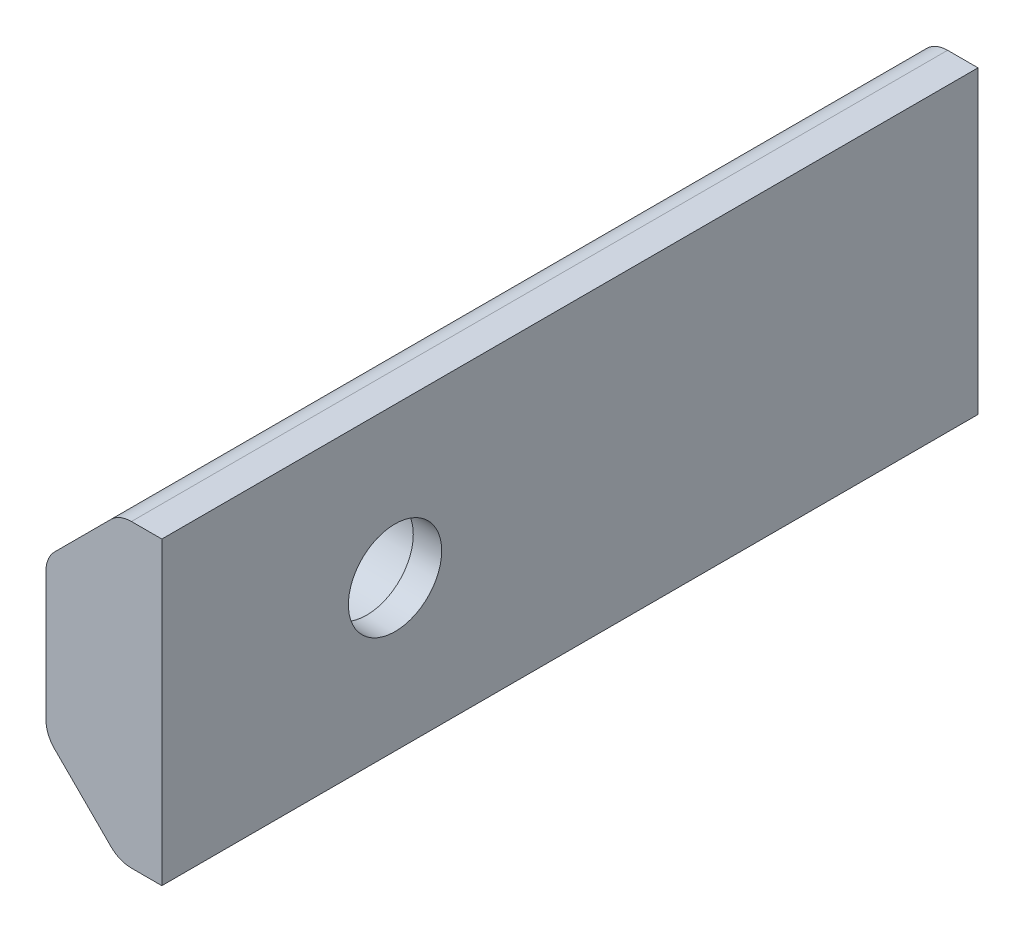
from build123d import *

# Parameters (mm, degrees)
BOSS_EXTRUDE1_DEPTH = 36
SKETCH2_R           = 1.6
CUT_EXTRUDE1_DEPTH  = 10
SKETCH3_R           = 1.95
CUT_EXTRUDE2_DEPTH  = 3
FILLET1_R           = 1
SKETCH4_W           = 8
SKETCH4_H           = 10.3
CUT_EXTRUDE3_DEPTH  = 10


with BuildPart() as part:
    # Sketch1 → Boss-Extrude1 (new body)
    with BuildSketch(Plane.XY):
        Polygon((1.933806537, 5.15), (1.933806537, -5.15), (0.476512405, -5.15), (-2.040358106, -2.633129489), (-2.040358106, 2.633129489), (0.476512405, 5.15), align=None)
    extrude(amount=BOSS_EXTRUDE1_DEPTH)

    # Sketch2 → Cut-Extrude1 (cut)
    with BuildSketch(Plane(origin=(1.933806537, 0, 0), x_dir=(0, 0, -1), z_dir=(1, 0, 0))):
        with Locations((-20, 0)):
            Circle(SKETCH2_R)
        with Locations((-31, 0)):
            Circle(SKETCH2_R)
    extrude(amount=-CUT_EXTRUDE1_DEPTH, mode=Mode.SUBTRACT)

    # Sketch3 → Cut-Extrude2 (cut)
    with BuildSketch(Plane.ZY.offset(2.040358106)):
        with Locations((20, 0)):
            Circle(SKETCH3_R)
        with Locations((31, 0)):
            Circle(SKETCH3_R)
    extrude(amount=-CUT_EXTRUDE2_DEPTH, mode=Mode.SUBTRACT)

    # Fillet1
    fillet1_edges = [part.edges().sort_by_distance(p)[0] for p in [
        (0.476512405, -5.15, 18),
        (-2.040358106, -2.633129489, 18),
        (-2.040358106, 2.633129489, 18),
        (0.476512405, 5.15, 18),
    ]]
    fillet(fillet1_edges, radius=FILLET1_R)

    # Sketch4 → Cut-Extrude3 (cut)
    with BuildSketch(Plane(origin=(1.933806537, 0, 0), x_dir=(0, 0, -1), z_dir=(1, 0, 0))):
        with Locations((-32, 0)):
            Rectangle(SKETCH4_W, SKETCH4_H)
    extrude(amount=-CUT_EXTRUDE3_DEPTH, mode=Mode.SUBTRACT)


solid = part.part
